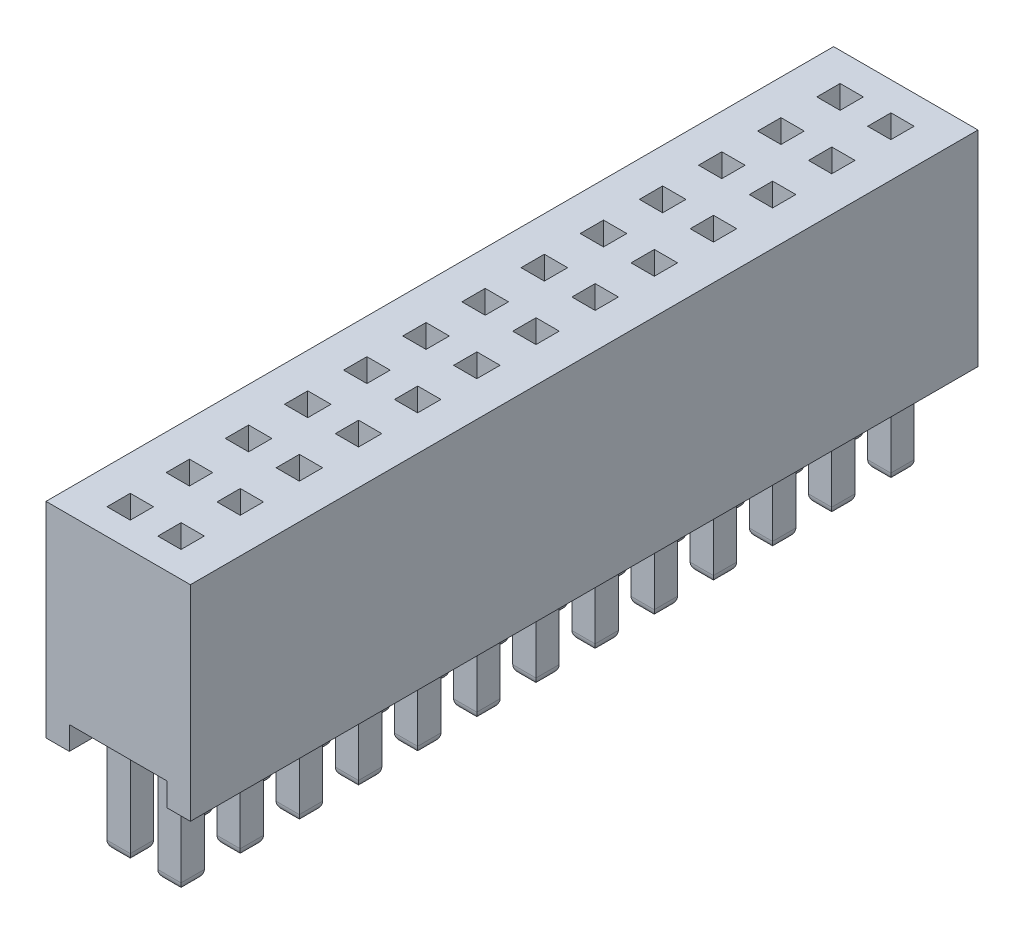
from build123d import *

# Parameters (mm, degrees)
BOSS_EXTRUDE1_DEPTH = 16.91
SKETCH4_W           = 0.5
SKETCH4_H           = 0.5
SKETCH4_W_2         = 0.498500791
CUT_EXTRUDE4_DEPTH  = 3.4
SKETCH5_W           = 0.498500791
SKETCH5_H           = 0.5
SKETCH5_W_2         = 0.5
BOSS_EXTRUDE3_DEPTH = 3
FILLET3_R           = 0.2


with BuildPart() as part:
    # Sketch1 → Boss-Extrude1 (new body)
    with BuildSketch(Plane.XY):
        Polygon((0.5, -4.4), (0.5, -3.9), (2.6, -3.9), (2.6, -4.4), (3.1, -4.4), (3.1, 0), (0, 0), (0, -4.4), align=None)
    extrude(amount=BOSS_EXTRUDE1_DEPTH)

    # Sketch4 → Cut-Extrude4 (cut)
    with BuildSketch(Plane(origin=(0, 0, 0), x_dir=(1, 0, 0), z_dir=(0, 1, 0))):
        with Locations((1.005, -2.135566851)):
            Rectangle(SKETCH4_W, SKETCH4_H)
        with Locations((1.005, -0.865566851)):
            Rectangle(SKETCH4_W, SKETCH4_H)
        with Locations((2.095749604, -2.135566851)):
            Rectangle(SKETCH4_W_2, SKETCH4_H)
        with Locations((2.095749604, -0.865566851)):
            Rectangle(SKETCH4_W_2, SKETCH4_H)
        with Locations((1.005, -3.405566851)):
            Rectangle(SKETCH4_W, SKETCH4_H)
        with Locations((2.095749604, -3.405566851)):
            Rectangle(SKETCH4_W_2, SKETCH4_H)
        with Locations((1.005, -4.675566851)):
            Rectangle(SKETCH4_W, SKETCH4_H)
        with Locations((2.095749604, -4.675566851)):
            Rectangle(SKETCH4_W_2, SKETCH4_H)
        with Locations((1.005, -5.945566851)):
            Rectangle(SKETCH4_W, SKETCH4_H)
        with Locations((2.095749604, -5.945566851)):
            Rectangle(SKETCH4_W_2, SKETCH4_H)
        with Locations((1.005, -7.215566851)):
            Rectangle(SKETCH4_W, SKETCH4_H)
        with Locations((2.095749604, -7.215566851)):
            Rectangle(SKETCH4_W_2, SKETCH4_H)
        with Locations((1.005, -8.485566851)):
            Rectangle(SKETCH4_W, SKETCH4_H)
        with Locations((2.095749604, -8.485566851)):
            Rectangle(SKETCH4_W_2, SKETCH4_H)
        with Locations((1.005, -9.755566851)):
            Rectangle(SKETCH4_W, SKETCH4_H)
        with Locations((2.095749604, -9.755566851)):
            Rectangle(SKETCH4_W_2, SKETCH4_H)
        with Locations((1.005, -11.025566851)):
            Rectangle(SKETCH4_W, SKETCH4_H)
        with Locations((2.095749604, -11.025566851)):
            Rectangle(SKETCH4_W_2, SKETCH4_H)
        with Locations((1.005, -12.295566851)):
            Rectangle(SKETCH4_W, SKETCH4_H)
        with Locations((2.095749604, -12.295566851)):
            Rectangle(SKETCH4_W_2, SKETCH4_H)
        with Locations((1.005, -13.565566851)):
            Rectangle(SKETCH4_W, SKETCH4_H)
        with Locations((2.095749604, -13.565566851)):
            Rectangle(SKETCH4_W_2, SKETCH4_H)
        with Locations((1.005, -14.835566851)):
            Rectangle(SKETCH4_W, SKETCH4_H)
        with Locations((2.095749604, -14.835566851)):
            Rectangle(SKETCH4_W_2, SKETCH4_H)
        with Locations((1.005, -16.105566851)):
            Rectangle(SKETCH4_W, SKETCH4_H)
        with Locations((2.095749604, -16.105566851)):
            Rectangle(SKETCH4_W_2, SKETCH4_H)
    extrude(amount=-CUT_EXTRUDE4_DEPTH, mode=Mode.SUBTRACT)

    # Sketch5 → Boss-Extrude3 (add)
    with BuildSketch(Plane(origin=(0, -3.4, 0), x_dir=(1, 0, 0), z_dir=(0, 1, 0))):
        with Locations((2.095749604, -2.135566851)):
            Rectangle(SKETCH5_W, SKETCH5_H)
        with Locations((1.005, -0.865566851)):
            Rectangle(SKETCH5_W_2, SKETCH5_H)
        with Locations((2.095749604, -0.865566851)):
            Rectangle(SKETCH5_W, SKETCH5_H)
        with Locations((1.005, -2.135566851)):
            Rectangle(SKETCH5_W_2, SKETCH5_H)
        with Locations((2.095749604, -3.405566851)):
            Rectangle(SKETCH5_W, SKETCH5_H)
        with Locations((1.005, -3.405566851)):
            Rectangle(SKETCH5_W_2, SKETCH5_H)
        with Locations((2.095749604, -4.675566851)):
            Rectangle(SKETCH5_W, SKETCH5_H)
        with Locations((1.005, -4.675566851)):
            Rectangle(SKETCH5_W_2, SKETCH5_H)
        with Locations((2.095749604, -5.945566851)):
            Rectangle(SKETCH5_W, SKETCH5_H)
        with Locations((1.005, -5.945566851)):
            Rectangle(SKETCH5_W_2, SKETCH5_H)
        with Locations((2.095749604, -7.215566851)):
            Rectangle(SKETCH5_W, SKETCH5_H)
        with Locations((1.005, -7.215566851)):
            Rectangle(SKETCH5_W_2, SKETCH5_H)
        with Locations((2.095749604, -8.485566851)):
            Rectangle(SKETCH5_W, SKETCH5_H)
        with Locations((1.005, -8.485566851)):
            Rectangle(SKETCH5_W_2, SKETCH5_H)
        with Locations((2.095749604, -9.755566851)):
            Rectangle(SKETCH5_W, SKETCH5_H)
        with Locations((1.005, -9.755566851)):
            Rectangle(SKETCH5_W_2, SKETCH5_H)
        with Locations((2.095749604, -11.025566851)):
            Rectangle(SKETCH5_W, SKETCH5_H)
        with Locations((1.005, -11.025566851)):
            Rectangle(SKETCH5_W_2, SKETCH5_H)
        with Locations((2.095749604, -12.295566851)):
            Rectangle(SKETCH5_W, SKETCH5_H)
        with Locations((1.005, -12.295566851)):
            Rectangle(SKETCH5_W_2, SKETCH5_H)
        with Locations((2.095749604, -13.565566851)):
            Rectangle(SKETCH5_W, SKETCH5_H)
        with Locations((1.005, -13.565566851)):
            Rectangle(SKETCH5_W_2, SKETCH5_H)
        with Locations((2.095749604, -14.835566851)):
            Rectangle(SKETCH5_W, SKETCH5_H)
        with Locations((1.005, -14.835566851)):
            Rectangle(SKETCH5_W_2, SKETCH5_H)
        with Locations((2.095749604, -16.105566851)):
            Rectangle(SKETCH5_W, SKETCH5_H)
        with Locations((1.005, -16.105566851)):
            Rectangle(SKETCH5_W_2, SKETCH5_H)
    extrude(amount=-BOSS_EXTRUDE3_DEPTH)

    # Fillet3
    fillet3_edges = [part.edges().sort_by_distance(p)[0] for p in [
        (0.755, -6.4, 0.865566851),
        (1.005, -6.4, 0.615566851),
        (1.255, -6.4, 0.865566851),
        (1.005, -6.4, 1.115566851),
        (1.846499209, -6.4, 0.865566851),
        (2.095749605, -6.4, 0.615566851),
        (2.345, -6.4, 0.865566851),
        (2.095749605, -6.4, 1.115566851),
        (0.755, -6.4, 2.135566851),
        (1.005, -6.4, 1.885566851),
        (1.255, -6.4, 2.135566851),
        (1.005, -6.4, 2.385566851),
        (1.846499209, -6.4, 2.135566851),
        (2.095749605, -6.4, 1.885566851),
        (2.345, -6.4, 2.135566851),
        (2.095749605, -6.4, 2.385566851),
        (0.755, -6.4, 3.405566851),
        (1.005, -6.4, 3.155566851),
        (1.255, -6.4, 3.405566851),
        (1.005, -6.4, 3.655566851),
        (1.846499209, -6.4, 3.405566851),
        (2.095749605, -6.4, 3.155566851),
        (2.345, -6.4, 3.405566851),
        (2.095749605, -6.4, 3.655566851),
        (0.755, -6.4, 4.675566851),
        (1.005, -6.4, 4.425566851),
        (1.255, -6.4, 4.675566851),
        (1.005, -6.4, 4.925566851),
        (1.846499209, -6.4, 4.675566851),
        (2.095749605, -6.4, 4.425566851),
        (2.345, -6.4, 4.675566851),
        (2.095749605, -6.4, 4.925566851),
        (0.755, -6.4, 5.945566851),
        (1.005, -6.4, 5.695566851),
        (1.255, -6.4, 5.945566851),
        (1.005, -6.4, 6.195566851),
        (1.846499209, -6.4, 5.945566851),
        (2.095749605, -6.4, 5.695566851),
        (2.345, -6.4, 5.945566851),
        (2.095749605, -6.4, 6.195566851),
        (0.755, -6.4, 7.215566851),
        (1.005, -6.4, 6.965566851),
        (1.255, -6.4, 7.215566851),
        (1.005, -6.4, 7.465566851),
        (1.846499209, -6.4, 7.215566851),
        (2.095749605, -6.4, 6.965566851),
        (2.345, -6.4, 7.215566851),
        (2.095749605, -6.4, 7.465566851),
        (0.755, -6.4, 8.485566851),
        (1.005, -6.4, 8.235566851),
        (1.255, -6.4, 8.485566851),
        (1.005, -6.4, 8.735566851),
        (1.846499209, -6.4, 8.485566851),
        (2.095749605, -6.4, 8.235566851),
        (2.345, -6.4, 8.485566851),
        (2.095749605, -6.4, 8.735566851),
        (0.755, -6.4, 9.755566851),
        (1.005, -6.4, 9.505566851),
        (1.255, -6.4, 9.755566851),
        (1.005, -6.4, 10.005566851),
        (1.846499209, -6.4, 9.755566851),
        (2.095749605, -6.4, 9.505566851),
        (2.345, -6.4, 9.755566851),
        (2.095749605, -6.4, 10.005566851),
        (0.755, -6.4, 11.025566851),
        (1.005, -6.4, 10.775566851),
        (1.255, -6.4, 11.025566851),
        (1.005, -6.4, 11.275566851),
        (1.846499209, -6.4, 11.025566851),
        (2.095749605, -6.4, 10.775566851),
        (2.345, -6.4, 11.025566851),
        (2.095749605, -6.4, 11.275566851),
        (0.755, -6.4, 12.295566851),
        (1.005, -6.4, 12.045566851),
        (1.255, -6.4, 12.295566851),
        (1.005, -6.4, 12.545566851),
        (1.846499209, -6.4, 12.295566851),
        (2.095749605, -6.4, 12.045566851),
        (2.345, -6.4, 12.295566851),
        (2.095749605, -6.4, 12.545566851),
        (0.755, -6.4, 13.565566851),
        (1.005, -6.4, 13.315566851),
        (1.255, -6.4, 13.565566851),
        (1.005, -6.4, 13.815566851),
        (1.846499209, -6.4, 13.565566851),
        (2.095749605, -6.4, 13.315566851),
        (2.345, -6.4, 13.565566851),
        (2.095749605, -6.4, 13.815566851),
        (0.755, -6.4, 14.835566851),
        (1.005, -6.4, 14.585566851),
        (1.255, -6.4, 14.835566851),
        (1.005, -6.4, 15.085566851),
        (1.846499209, -6.4, 14.835566851),
        (2.095749605, -6.4, 14.585566851),
        (2.345, -6.4, 14.835566851),
        (2.095749605, -6.4, 15.085566851),
        (0.755, -6.4, 16.105566851),
        (1.005, -6.4, 15.855566851),
        (1.255, -6.4, 16.105566851),
        (1.005, -6.4, 16.355566851),
        (1.846499209, -6.4, 16.105566851),
        (2.095749605, -6.4, 15.855566851),
        (2.345, -6.4, 16.105566851),
        (2.095749605, -6.4, 16.355566851),
    ]]
    fillet(fillet3_edges, radius=FILLET3_R)


solid = part.part
